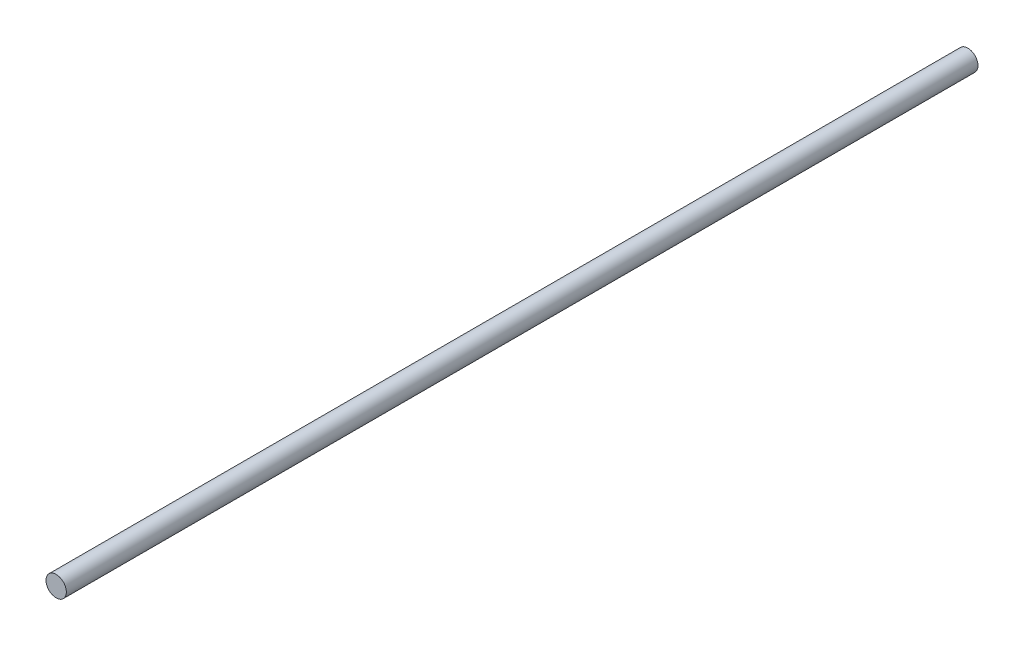
from build123d import *

# Parameters (mm, degrees)
SKETCH1_R           = 3.7970867
BOSS_EXTRUDE1_DEPTH = 300
BOSS_EXTRUDE2_START = 40
SKETCH1_2_R         = 3.7970867
BOSS_EXTRUDE2_DEPTH = 40


with BuildPart() as part:
    # Sketch1 → Boss-Extrude1 (new body)
    with BuildSketch(Plane.XY):
        with Locations((10.016557459, -10.016557459)):
            Circle(SKETCH1_R)
    extrude(amount=-BOSS_EXTRUDE1_DEPTH)

    # Sketch1_2 → Boss-Extrude2 (add)
    with BuildSketch(Plane.XY.offset(BOSS_EXTRUDE2_START)):
        with Locations((10.016557459, -10.016557459)):
            Circle(SKETCH1_2_R)
    extrude(amount=-BOSS_EXTRUDE2_DEPTH)


solid = part.part
